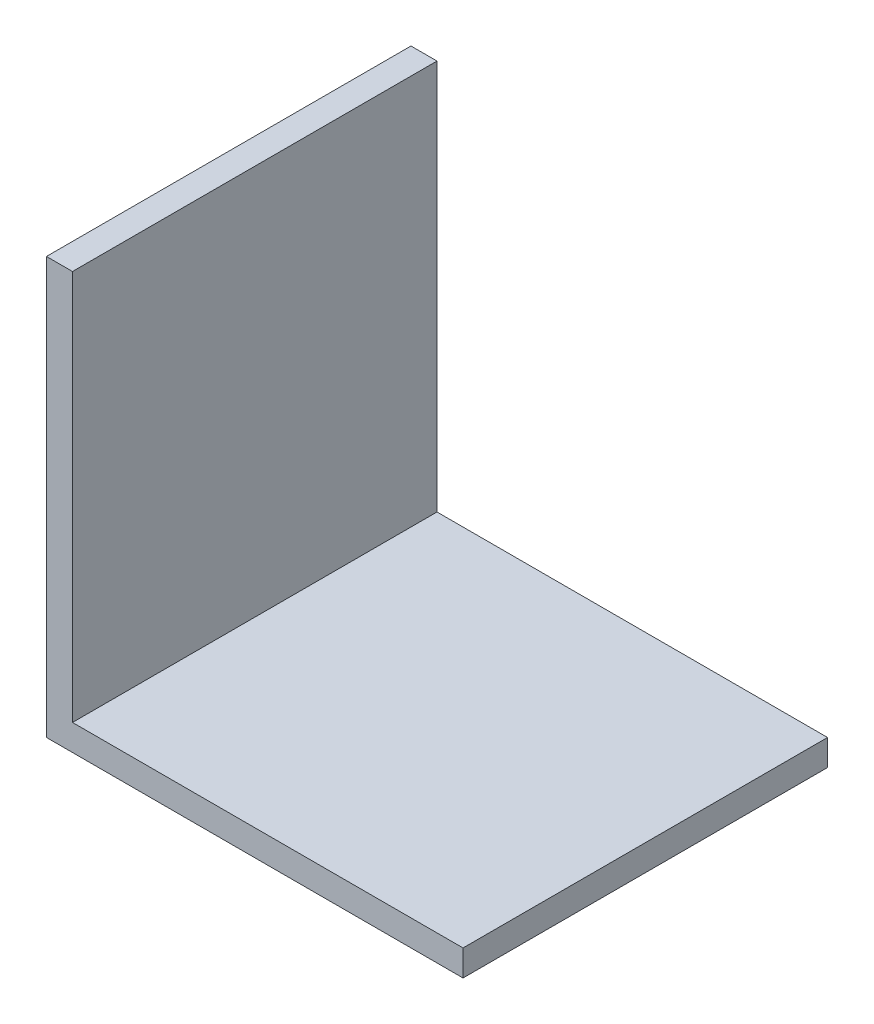
from build123d import *

# Parameters (mm, degrees)
BOSS_EXTRUDE1_DEPTH = 33.3375


with BuildPart() as part:
    # Sketch2 → Boss-Extrude1 (new body, symmetric)
    with BuildSketch(Plane.XY):
        Polygon((0, 0), (0, 76.2), (4.7625, 76.2), (4.7625, 4.7625), (76.2, 4.7625), (76.2, 0), align=None)
    extrude(amount=BOSS_EXTRUDE1_DEPTH, both=True)


solid = part.part
